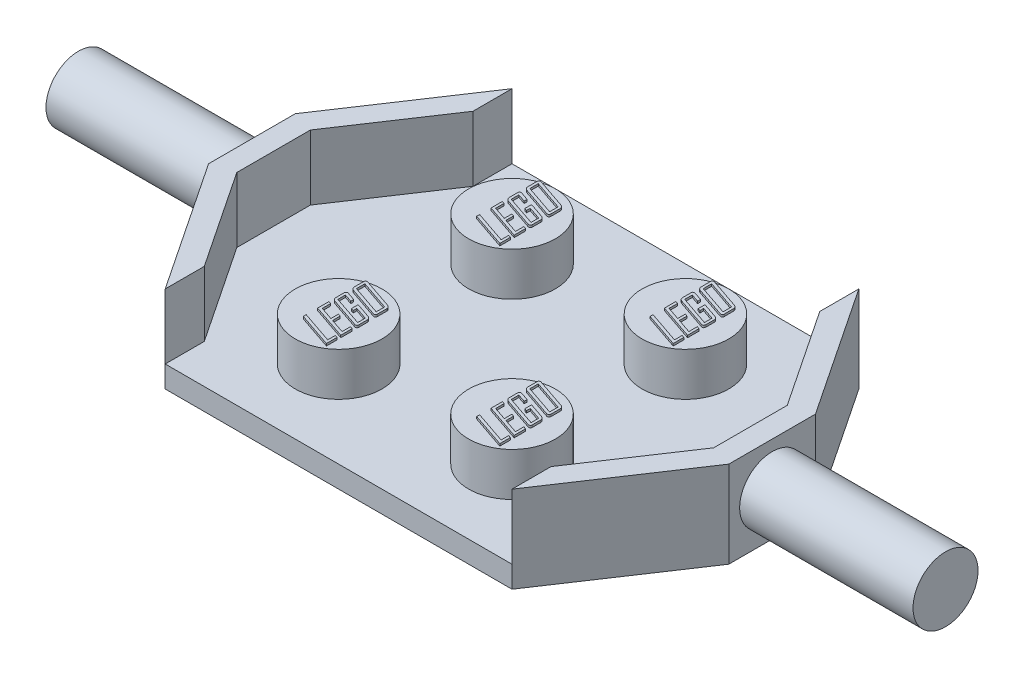
from build123d import *

# Parameters (mm, degrees)
BOSS_EXTRUDE1_DEPTH  = 1
SKETCH2_R            = 2
BOSS_EXTRUDE2_DEPTH  = 2
BOSS_EXTRUDE3_DEPTH  = 3
SKETCH4_R            = 1.5
BOSS_EXTRUDE4_DEPTH  = 8
BOSS_EXTRUDE5_DEPTH  = 0.1
LPATTERN1_COUNT      = 2
LPATTERN1_PITCH      = 8
LPATTERN1_COUNT_DIR2 = 2
LPATTERN1_PITCH_DIR2 = 8


with BuildPart() as part:
    # Sketch1 → Boss-Extrude1 (new body)
    with BuildSketch(Plane(origin=(0, 0, 0), x_dir=(1, 0, 0), z_dir=(0, 1, 0))):
        Polygon((-12, -2), (-12, 2), (-8, 8), (0, 8), (0, -8), (-8, -8), align=None)
    extrude(amount=BOSS_EXTRUDE1_DEPTH)

    # Sketch2 → Boss-Extrude2 (add)
    with BuildSketch(Plane(origin=(0, 1, 0), x_dir=(1, 0, 0), z_dir=(0, 1, 0))):
        with Locations((-4, 4)):
            Circle(SKETCH2_R)
        with Locations((-4, -4)):
            Circle(SKETCH2_R)
    extrude(amount=BOSS_EXTRUDE2_DEPTH)

    # Sketch3 → Boss-Extrude3 (add)
    with BuildSketch(Plane(origin=(0, 1, 0), x_dir=(1, 0, 0), z_dir=(0, 1, 0))):
        Polygon((-12, -2), (-8, -8), (-8, -6.197224362), (-11, -1.697224362), (-11, 1.697224362), (-8, 6.197224362), (-8, 8), (-12, 2), align=None)
    extrude(amount=BOSS_EXTRUDE3_DEPTH)

    # Sketch4 → Boss-Extrude4 (add)
    with BuildSketch(Plane.ZY.offset(12)):
        with Locations((0, 2)):
            Circle(SKETCH4_R)
    extrude(amount=BOSS_EXTRUDE4_DEPTH)

    # Mirror1: part across plane


with BuildPart() as part_1:
    add(part.part)
    add(part.part.mirror(Plane(origin=(0, 0, 0), x_dir=(0, 0, 1), z_dir=(1, 0, 0))))

    # Sketch5 → Boss-Extrude5 (add)
    with BuildSketch(Plane(origin=(0, 3, 0), x_dir=(1, 0, 0), z_dir=(0, 1, 0))):
        Polygon((-3, -5.07639621), (-3, -5.563586671), (-4.617472331, -5.013974932), (-4.617472331, -4.877561603), (-3.116925711, -5.387284623), (-3.116925711, -5.036507491), align=None)
        Polygon((-3, -4.375816327), (-3, -4.901982025), (-4.617472331, -4.352370286), (-4.617472331, -3.826204588), (-4.50054662, -3.865788813), (-4.50054662, -4.255541182), (-3.896430448, -4.460770163), (-3.896430448, -4.109993032), (-3.779504738, -4.149881751), (-3.779504738, -4.500658882), (-3.116925711, -4.725679977), (-3.116925711, -4.335927608), align=None)
        with BuildLine():
            add(Edge.make_bspline(
                [(-3.119361663, -3.517813026), (-3.110800141, -3.521081683), (-3.093957071, -3.527512106), (-3.071136724, -3.542064932), (-3.050497165, -3.559372092), (-3.033052828, -3.580182774), (-3.018500741, -3.602746648), (-3.007534489, -3.626650767), (-3.001277974, -3.651879609), (-3.000429102, -3.669012008), (-3, -3.677672396)],
                knots=[0, 0, 0, 0, 2.7428e-05, 5.3959e-05, 8.0744e-05, 0.000107959, 0.000135072, 0.000161104, 0.000186509, 0.000212479, 0.000212479, 0.000212479, 0.000212479], degree=3))
            Line((-3, -3.677672396), (-3, -4.06255286))
            add(Edge.make_bspline(
                [(-3, -4.06255286), (-3.000393246, -4.070705946), (-3.001133583, -4.086055188), (-3.007020863, -4.107517184), (-3.018155678, -4.124889212), (-3.032963953, -4.138214779), (-3.051198157, -4.147092769), (-3.072180736, -4.150147032), (-3.095408139, -4.148459065), (-3.111004717, -4.143873728), (-3.119361663, -4.141416816)],
                knots=[0, 0, 0, 0, 2.4453e-05, 4.6035e-05, 6.5886e-05, 8.5509e-05, 0.000105119, 0.000125794, 0.000148378, 0.000174447, 0.000174447, 0.000174447, 0.000174447], degree=3))
            Line((-3.119361663, -4.141416816), (-4.498110668, -3.672800492))
            add(Edge.make_bspline(
                [(-4.498110668, -3.672800492), (-4.5066755, -3.669536063), (-4.523525082, -3.663113957), (-4.546242298, -3.648535645), (-4.567072315, -3.631470812), (-4.584695841, -3.610808853), (-4.59943062, -3.588179121), (-4.609796412, -3.56395811), (-4.616226976, -3.53874798), (-4.617054181, -3.521606234), (-4.617472331, -3.512941121)],
                knots=[0, 0, 0, 0, 2.7428e-05, 5.3959e-05, 8.0548e-05, 0.000107961, 0.000135075, 0.000161263, 0.000186668, 0.000212637, 0.000212637, 0.000212637, 0.000212637], degree=3))
            Line((-4.617472331, -3.512941121), (-4.617472331, -3.128060657))
            add(Edge.make_bspline(
                [(-4.617472331, -3.128060657), (-4.617089341, -3.119900586), (-4.616368314, -3.104538193), (-4.610367358, -3.083216169), (-4.599752475, -3.065643916), (-4.584628573, -3.052622347), (-4.566328347, -3.043968349), (-4.545330206, -3.040338163), (-4.522057661, -3.042193312), (-4.506465336, -3.046753347), (-4.498110668, -3.049196701)],
                knots=[0, 0, 0, 0, 2.4453e-05, 4.6035e-05, 6.5724e-05, 8.5145e-05, 0.00010503, 0.000125756, 0.00014834, 0.00017441, 0.00017441, 0.00017441, 0.00017441], degree=3))
            Line((-4.498110668, -3.049196701), (-4.13028187, -3.174039257))
            Line((-4.13028187, -3.174039257), (-4.13028187, -3.310452586))
            Line((-4.13028187, -3.310452586), (-4.50054662, -3.184696548))
            Line((-4.50054662, -3.184696548), (-4.50054662, -3.53547368))
            Line((-4.50054662, -3.53547368), (-3.116925711, -4.005612475))
            Line((-3.116925711, -4.005612475), (-3.116925711, -3.654835343))
            Line((-3.116925711, -3.654835343), (-3.701554264, -3.45630523))
            Line((-3.701554264, -3.45630523), (-3.701554264, -3.631693796))
            Line((-3.701554264, -3.631693796), (-3.818479975, -3.591805077))
            Line((-3.818479975, -3.591805077), (-3.818479975, -3.280003182))
            Line((-3.818479975, -3.280003182), (-3.119361663, -3.517813026))
        make_face()
        with BuildLine():
            add(Edge.make_bspline(
                [(-3.119361663, -2.622356959), (-3.110800151, -2.625625617), (-3.093957099, -2.632056045), (-3.071136615, -2.646608841), (-3.050497579, -2.663916116), (-3.033051257, -2.684726357), (-3.01850648, -2.707291854), (-3.007472842, -2.731280171), (-3.001338446, -2.756537274), (-3.00044595, -2.773660455), (-3, -2.782216329)],
                knots=[0, 0, 0, 0, 2.7428e-05, 5.3959e-05, 8.0744e-05, 0.000107959, 0.000135072, 0.000161104, 0.000186805, 0.000212471, 0.000212471, 0.000212471, 0.000212471], degree=3))
            Line((-3, -2.782216329), (-3, -3.20607203))
            add(Edge.make_bspline(
                [(-3, -3.20607203), (-3.000393246, -3.214225115), (-3.001133583, -3.229574358), (-3.007020863, -3.251036354), (-3.018155678, -3.268408381), (-3.032963953, -3.281733948), (-3.051198157, -3.290611938), (-3.072180736, -3.293666201), (-3.095408139, -3.291978234), (-3.111004717, -3.287392897), (-3.119361663, -3.284935986)],
                knots=[0, 0, 0, 0, 2.4453e-05, 4.6035e-05, 6.5886e-05, 8.5509e-05, 0.000105119, 0.000125794, 0.000148378, 0.000174447, 0.000174447, 0.000174447, 0.000174447], degree=3))
            Line((-3.119361663, -3.284935986), (-4.498110668, -2.816319661))
            add(Edge.make_bspline(
                [(-4.498110668, -2.816319661), (-4.5066755, -2.813055232), (-4.523525082, -2.806633127), (-4.546242298, -2.792054815), (-4.567072315, -2.774989982), (-4.584695841, -2.754328023), (-4.59943062, -2.731698291), (-4.609796412, -2.707477279), (-4.616226976, -2.682267149), (-4.617054181, -2.665125404), (-4.617472331, -2.656460291)],
                knots=[0, 0, 0, 0, 2.7428e-05, 5.3959e-05, 8.0548e-05, 0.000107961, 0.000135075, 0.000161263, 0.000186668, 0.000212637, 0.000212637, 0.000212637, 0.000212637], degree=3))
            Line((-4.617472331, -2.656460291), (-4.617472331, -2.23260459))
            add(Edge.make_bspline(
                [(-4.617472331, -2.23260459), (-4.617101546, -2.224442674), (-4.616407921, -2.209174255), (-4.610314395, -2.187965858), (-4.599661904, -2.170499732), (-4.584741376, -2.157137097), (-4.56631393, -2.148528669), (-4.545334491, -2.144877225), (-4.522056351, -2.146738734), (-4.506464879, -2.151297799), (-4.498110668, -2.153740634)],
                knots=[0, 0, 0, 0, 2.4453e-05, 4.5743e-05, 6.5432e-05, 8.5055e-05, 0.00010494, 0.000125666, 0.00014825, 0.000174319, 0.000174319, 0.000174319, 0.000174319], degree=3))
            Line((-4.498110668, -2.153740634), (-3.119361663, -2.622356959))
        make_face()
        Polygon((-3.116925711, -2.759379276), (-4.50054662, -2.289240481), (-4.50054662, -2.67899285), (-3.116925711, -3.149131645), align=None, mode=Mode.SUBTRACT)
    boss_extrude5 = extrude(amount=BOSS_EXTRUDE5_DEPTH)

    # LPattern1: Boss-Extrude5 2 × 2
    with Locations(*[(j * LPATTERN1_PITCH_DIR2, 0, -i * LPATTERN1_PITCH) for i in range(LPATTERN1_COUNT) for j in range(LPATTERN1_COUNT_DIR2) if (i, j) != (0, 0)]):
        add(boss_extrude5)


solid = part_1.part
